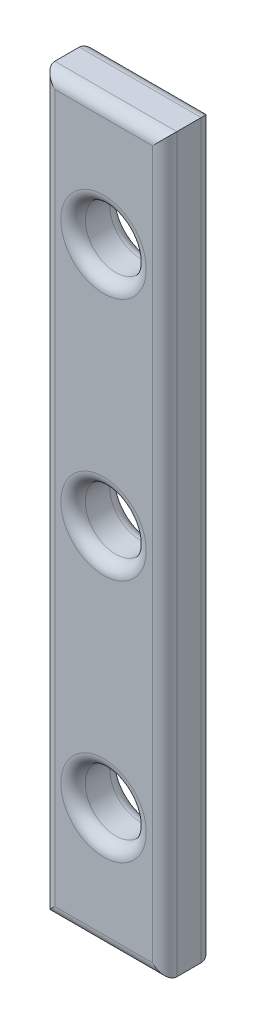
from build123d import *

# Parameters (mm, degrees)
SKETCH2_W           = 10
SKETCH2_H           = 60
SKETCH2_R           = 2.5
BOSS_EXTRUDE1_DEPTH = 4
FILLET1_R           = 1
FILLET2_R           = 1


with BuildPart() as part:
    # Sketch2 → Boss-Extrude1 (new body)
    with BuildSketch(Plane.XY):
        with Locations((5, 30)):
            Rectangle(SKETCH2_W, SKETCH2_H)
        with Locations((5, 50)):
            Circle(SKETCH2_R, mode=Mode.SUBTRACT)
        with Locations((5, 10)):
            Circle(SKETCH2_R, mode=Mode.SUBTRACT)
        with Locations((5, 30)):
            Circle(SKETCH2_R, mode=Mode.SUBTRACT)
    extrude(amount=BOSS_EXTRUDE1_DEPTH)

    # Fillet1
    fillet1_edges = [part.edges().sort_by_distance(p)[0] for p in [
        (2.5, 30, 4),
        (10, 30, 4),
        (2.5, 50, 0),
        (2.5, 50, 4),
        (5, 60, 4),
        (2.5, 10, 0),
        (2.5, 10, 4),
        (0, 30, 4),
        (5, 60, 0),
        (10, 30, 0),
        (5, 0, 0),
        (0, 30, 0),
        (5, 0, 4),
    ]]
    fillet(fillet1_edges, radius=FILLET1_R)

    # Fillet2
    fillet2_edges = [part.edges().sort_by_distance(p)[0] for p in [
        (2.5, 30, 0),
    ]]
    fillet(fillet2_edges, radius=FILLET2_R)


solid = part.part
